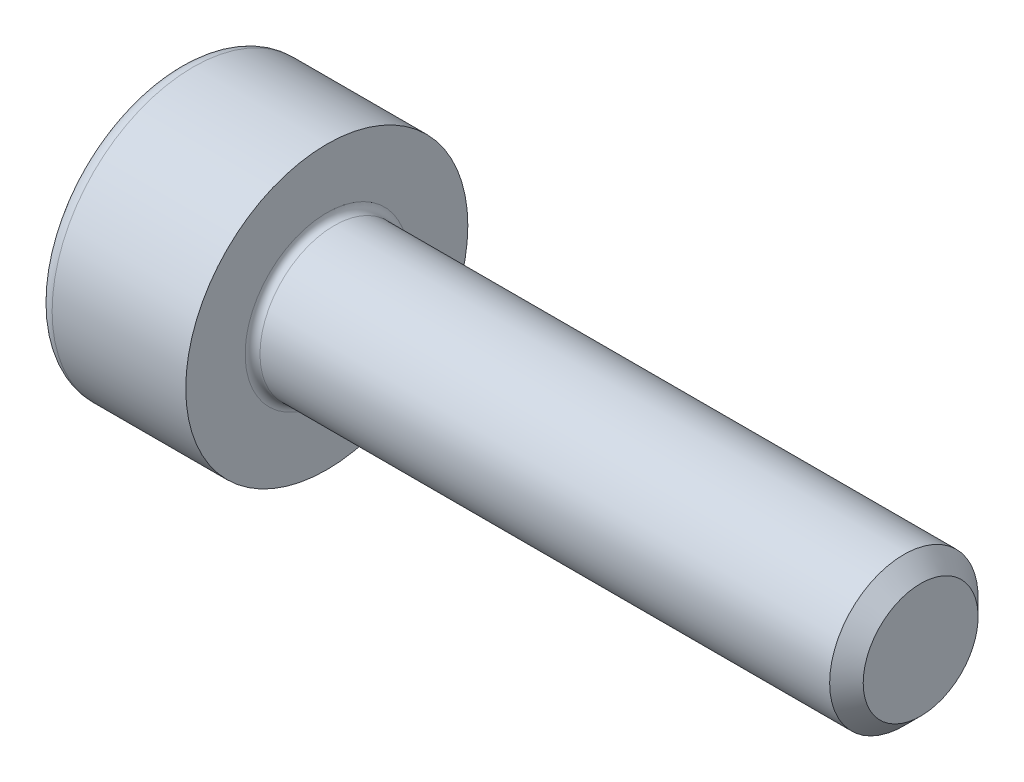
from build123d import *

# Parameters (mm, degrees)
FILLET1_R   = 0.1
FILLET2_R   = 0.2
HEX_2_DEPTH = 1


with BuildPart() as part:
    # BodySke → Base-Revolve (revolve)
    with BuildSketch(Plane.XY):
        Polygon((0, 0), (0, 1.9), (2, 1.9), (2, 1), (9.774, 1), (10, 0.774), (10, 0), align=None)
    revolve(axis=Axis((-31.75, 0, 0), (1, 0, 0)))

    # Fillet1
    fillet1_edges = [part.edges().sort_by_distance(p)[0] for p in [
        (2, -1, 0),
    ]]
    fillet(fillet1_edges, radius=FILLET1_R)

    # Fillet2
    fillet2_edges = [part.edges().sort_by_distance(p)[0] for p in [
        (0, -1.9, 0),
    ]]
    fillet(fillet2_edges, radius=FILLET2_R)

    # Sketch2 → Hex-PreBroach (revolve, cut)
    with BuildSketch(Plane.XY):
        Polygon((0, 0.76), (1, 0.76), (1.438786205, 0), (0, 0), align=None)
    revolve(axis=Axis((0, 0, 0), (1, 0, 0)), mode=Mode.SUBTRACT)

    # Sketch3 → Hex 2 (cut)
    with BuildSketch(Plane(origin=(0, 0, 0), x_dir=(0, 0.5, 0.866025404), z_dir=(-1, 0, 0))):
        Polygon((0.438786205, 0.76), (-0.438786205, 0.76), (-0.877572409, 0), (-0.438786205, -0.76), (0.438786205, -0.76), (0.877572409, 0), align=None)
    extrude(amount=-HEX_2_DEPTH, mode=Mode.SUBTRACT)


solid = part.part
